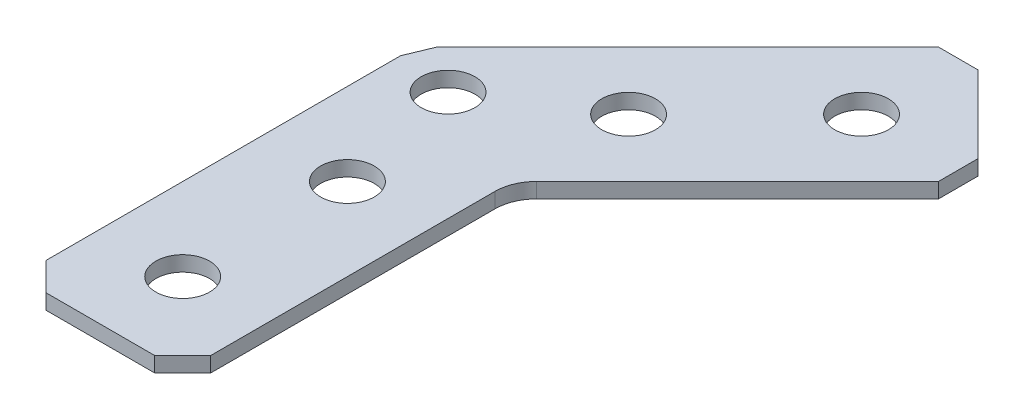
from build123d import *

# Parameters (mm, degrees)
SKETCH1_R           = 2.0701
BOSS_EXTRUDE1_DEPTH = 1.1684


with BuildPart() as part:
    # Sketch1 → Boss-Extrude1 (new body)
    with BuildSketch(Plane(origin=(0, 1.1684, 0), x_dir=(1, 0, 0), z_dir=(0, 1, 0))):
        with BuildLine():
            Line((16.856899662, 38.114124823), (13.80361258, 38.114124823))
            Line((13.80361258, 38.114124823), (-5.52378647, 18.786725773))
            Line((-5.52378647, 18.786725773), (-6.35, 16.792069862))
            Line((-6.35, 16.792069862), (-6.35, -10.541))
            Line((-6.35, -10.541), (-4.191, -12.7))
            Line((-4.191, -12.7), (4.191, -12.7))
            Line((4.191, -12.7), (6.35, -10.541))
            Line((6.35, -10.541), (6.35, 11.384871939))
            ThreePointArc((6.35, 11.384871939), (6.591682484, 12.599891837), (7.27993597, 13.62993597))
            Line((7.27993597, 13.62993597), (22.783868702, 29.133868702))
            Line((22.783868702, 29.133868702), (22.783868702, 32.187155783))
            Line((22.783868702, 32.187155783), (16.856899662, 38.114124823))
        make_face()
        with Locations((15.330256121, 30.660512242)):
            Circle(SKETCH1_R, mode=Mode.SUBTRACT)
        with Locations((0, 6.35)):
            Circle(SKETCH1_R, mode=Mode.SUBTRACT)
        with Locations((-2.085466914, 16.194084801)):
            Circle(SKETCH1_R, mode=Mode.SUBTRACT)
        with Locations((0, -6.35)):
            Circle(SKETCH1_R, mode=Mode.SUBTRACT)
        with Locations((6.35, 21.680256121)):
            Circle(SKETCH1_R, mode=Mode.SUBTRACT)
    extrude(amount=-BOSS_EXTRUDE1_DEPTH)


solid = part.part
